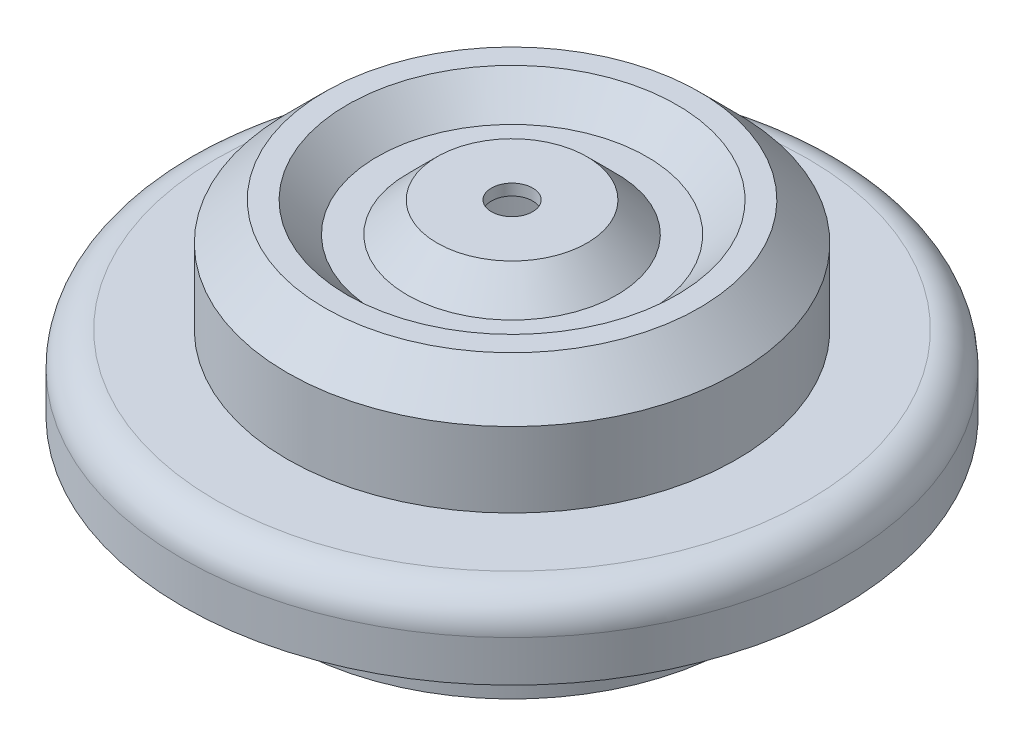
from build123d import *

# Parameters (mm, degrees)
SKETCH_2_R          = 2.75
CUT_EXTRUDE_1_DEPTH = 26
SKETCH_3_R          = 30
SKETCH_3_R_2        = 28.5
EXTRUDE_1_DEPTH     = 20


with BuildPart() as part:
    # Эскиз1 → Повернуть2 (revolve)
    with BuildSketch(Plane.XY):
        with BuildLine():
            Line((0, 0), (10, 0))
            Line((10, 0), (14, -4))
            Line((14, -4), (18, -4))
            Line((18, -4), (22, 0))
            Line((22, 0), (25, 0))
            Line((25, 0), (30, -5))
            Line((30, -5), (30, -15))
            Line((30, -15), (39.5, -15))
            ThreePointArc((39.5, -15), (42.681980515, -16.318019485), (44, -19.5))
            Line((44, -19.5), (44, -25))
            Line((44, -25), (42.5, -25))
            Line((42.5, -25), (42.5, -19.5))
            ThreePointArc((42.5, -19.5), (41.621320344, -17.378679656), (39.5, -16.5))
            Line((39.5, -16.5), (28.5, -16.5))
            Line((28.5, -16.5), (28.5, -5.621320344))
            Line((28.5, -5.621320344), (24.378679656, -1.5))
            Line((24.378679656, -1.5), (22.621320344, -1.5))
            Line((22.621320344, -1.5), (18.621320344, -5.5))
            Line((18.621320344, -5.5), (13.378679656, -5.5))
            Line((13.378679656, -5.5), (9.378679656, -1.5))
            Line((9.378679656, -1.5), (0, -1.5))
            Line((0, -1.5), (0, 0))
        make_face()
    revolve(axis=Axis((0, 0, 0), (0, -1, 0)))

    # Эскиз2 → Вырез-Вытянуть1 (cut, through all)
    with BuildSketch(Plane(origin=(0, 0, 0), x_dir=(1, 0, 0), z_dir=(0, 1, 0))):
        Circle(SKETCH_2_R)
    extrude(amount=-CUT_EXTRUDE_1_DEPTH, mode=Mode.SUBTRACT)

    # Эскиз3 → Бобышка-Вытянуть1 (add)
    with BuildSketch(Plane.XZ.offset(16.5)):
        Circle(SKETCH_3_R)
        Circle(SKETCH_3_R_2, mode=Mode.SUBTRACT)
    extrude(amount=EXTRUDE_1_DEPTH)


solid = part.part
